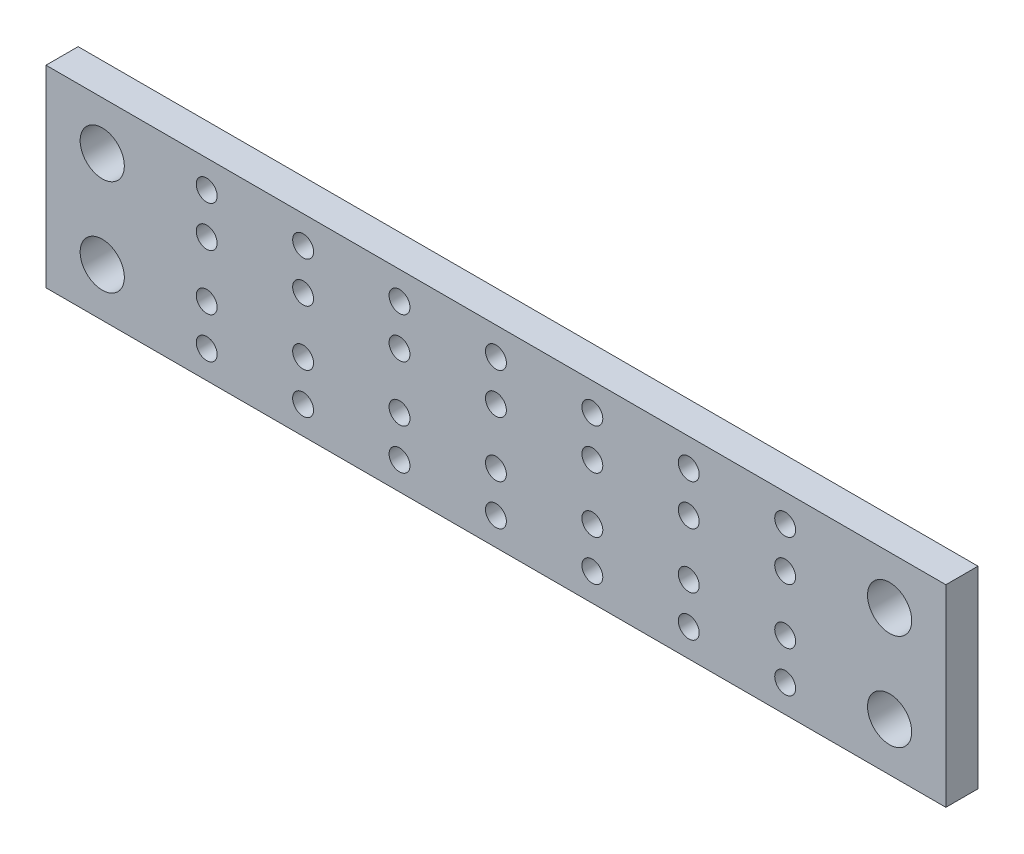
from build123d import *

# Parameters (mm, degrees)
SKETCH1_W           = 42
SKETCH1_H           = 12
TAILLIGHTBASE_DEPTH = 2
SKETCH2_R           = 0.65
LEDMOUNTS_DEPTH     = 2
SKETCH3_W           = 7
SKETCH3_H           = 12
MOUNTINGTABS_DEPTH  = 2
SKETCH4_R           = 1.375
MOUNTINGHOLES_DEPTH = 2


with BuildPart() as part:
    # Sketch1 → tailLightBase (new body)
    with BuildSketch(Plane.XY):
        with Locations((21, 6)):
            Rectangle(SKETCH1_W, SKETCH1_H)
    extrude(amount=TAILLIGHTBASE_DEPTH)

    # Sketch2 → ledMounts (cut)
    with BuildSketch(Plane.XY.offset(2)):
        with Locations((3, 10.27)):
            Circle(SKETCH2_R)
        with Locations((3, 7.73)):
            Circle(SKETCH2_R)
        with Locations((9, 10.27)):
            Circle(SKETCH2_R)
        with Locations((9, 7.73)):
            Circle(SKETCH2_R)
        with Locations((15, 10.27)):
            Circle(SKETCH2_R)
        with Locations((15, 7.73)):
            Circle(SKETCH2_R)
        with Locations((21, 10.27)):
            Circle(SKETCH2_R)
        with Locations((21, 7.73)):
            Circle(SKETCH2_R)
        with Locations((27, 10.27)):
            Circle(SKETCH2_R)
        with Locations((27, 7.73)):
            Circle(SKETCH2_R)
        with Locations((33, 10.27)):
            Circle(SKETCH2_R)
        with Locations((33, 7.73)):
            Circle(SKETCH2_R)
        with Locations((39, 10.27)):
            Circle(SKETCH2_R)
        with Locations((39, 7.73)):
            Circle(SKETCH2_R)
        with Locations((39, 4.27)):
            Circle(SKETCH2_R)
        with Locations((39, 1.73)):
            Circle(SKETCH2_R)
        with Locations((33, 1.73)):
            Circle(SKETCH2_R)
        with Locations((33, 4.27)):
            Circle(SKETCH2_R)
        with Locations((27, 4.27)):
            Circle(SKETCH2_R)
        with Locations((27, 1.73)):
            Circle(SKETCH2_R)
        with Locations((21, 4.27)):
            Circle(SKETCH2_R)
        with Locations((21, 1.73)):
            Circle(SKETCH2_R)
        with Locations((15, 4.27)):
            Circle(SKETCH2_R)
        with Locations((15, 1.73)):
            Circle(SKETCH2_R)
        with Locations((9, 1.73)):
            Circle(SKETCH2_R)
        with Locations((9, 4.27)):
            Circle(SKETCH2_R)
        with Locations((3, 1.73)):
            Circle(SKETCH2_R)
        with Locations((3, 4.27)):
            Circle(SKETCH2_R)
    extrude(amount=-LEDMOUNTS_DEPTH, mode=Mode.SUBTRACT)

    # Sketch3 → mountingTabs (add)
    with BuildSketch(Plane.XY.offset(2)):
        with Locations((-3.5, 6)):
            Rectangle(SKETCH3_W, SKETCH3_H)
        with Locations((45.5, 6)):
            Rectangle(SKETCH3_W, SKETCH3_H)
    extrude(amount=-MOUNTINGTABS_DEPTH)

    # Sketch4 → mountingHoles (cut)
    with BuildSketch(Plane.XY.offset(2)):
        with Locations((-3.5, 9)):
            Circle(SKETCH4_R)
        with Locations((45.5, 9)):
            Circle(SKETCH4_R)
        with Locations((-3.5, 3)):
            Circle(SKETCH4_R)
        with Locations((45.5, 3)):
            Circle(SKETCH4_R)
    extrude(amount=-MOUNTINGHOLES_DEPTH, mode=Mode.SUBTRACT)


solid = part.part
